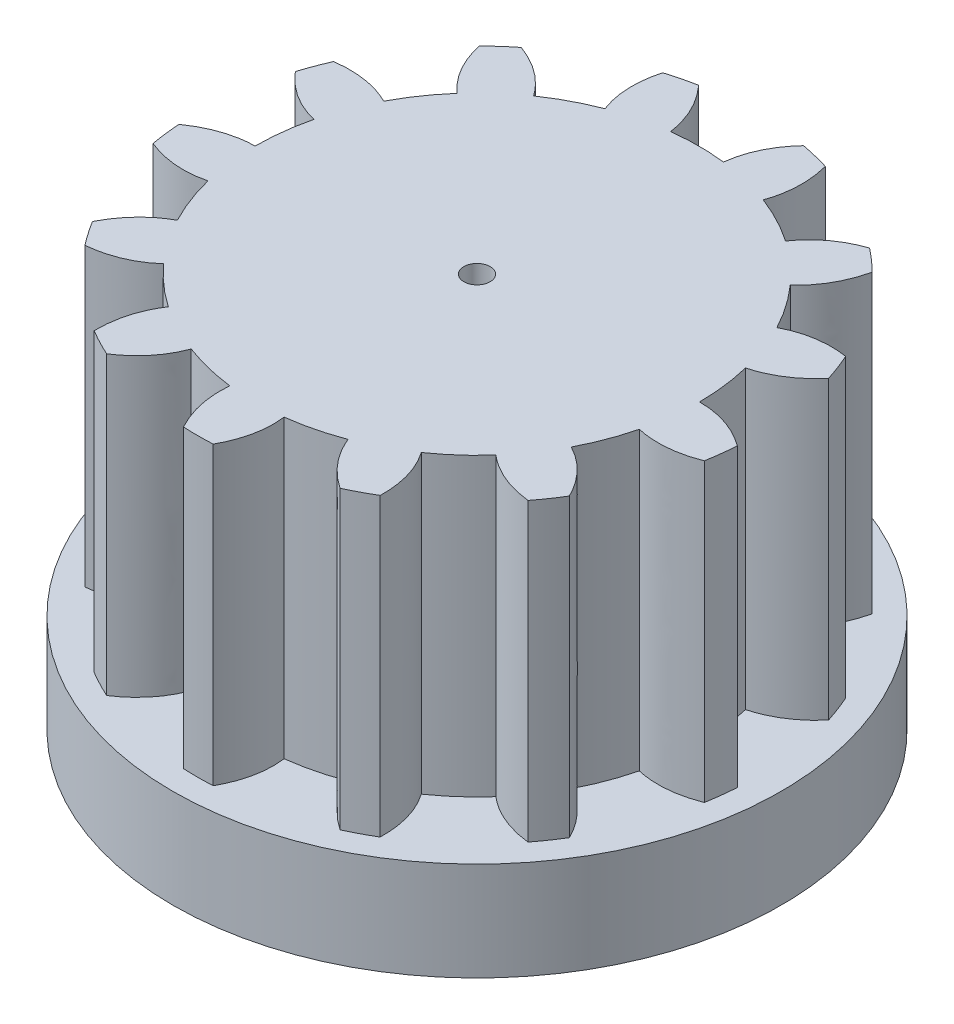
from build123d import *

# Parameters (mm, degrees)
SKETCH1_R           = 0.4
BOSS_EXTRUDE1_DEPTH = 9
SKETCH2_R           = 9.25
BOSS_EXTRUDE2_DEPTH = 3


with BuildPart() as part:
    # Sketch1 → Boss-Extrude1 (new body)
    with BuildSketch(Plane(origin=(0, 0, 0), x_dir=(1, 0, 0), z_dir=(0, 1, 0))):
        with BuildLine():
            add(Edge.make_bspline(
                [(-5.065227978, 4.461610195), (-5.526615005, 4.86619147), (-5.830003112, 5.39406146), (-5.975392301, 6.045220165)],
                knots=[0, 0, 0, 0, 0.872429449, 0.872429449, 0.872429449, 0.872429449], degree=3))
            ThreePointArc((-5.065227978, 4.461610195), (-5.560258819, 3.827012132), (-5.976238464, 3.138004752))
            add(Edge.make_bspline(
                [(-7.780961116, 3.42149735), (-7.125870497, 3.507536778), (-6.52429628, 3.413039245), (-5.976238464, 3.138004752)],
                knots=[0.127683247, 0.127683247, 0.127683247, 0.127683247, 1, 1, 1, 1], degree=3))
            ThreePointArc((-7.780961116, 3.42149735), (-7.951879756, 3.00293329), (-8.10030101, 2.575873357))
            add(Edge.make_bspline(
                [(-6.558450277, 1.596630818), (-7.155006493, 1.740452504), (-7.668956737, 2.066866683), (-8.10030101, 2.575873357)],
                knots=[0, 0, 0, 0, 0.872429449, 0.872429449, 0.872429449, 0.872429449], degree=3))
            ThreePointArc((-6.558450277, 1.596630818), (-6.701865893, 0.804669837), (-6.749999881, 0.00126872))
            add(Edge.make_bspline(
                [(-8.479748007, -0.586407486), (-7.939678588, -0.205787566), (-7.363095879, -0.009895497), (-6.749999881, 0.00126872)],
                knots=[0.127683247, 0.127683247, 0.127683247, 0.127683247, 1, 1, 1, 1], degree=3))
            ThreePointArc((-8.479748007, -0.586407486), (-8.436572529, -1.036457408), (-8.369528376, -1.483574994))
            add(Edge.make_bspline(
                [(-6.549210655, -1.634117437), (-7.144272221, -1.784003157), (-7.751044795, -1.733822342), (-8.369528376, -1.483574994)],
                knots=[0, 0, 0, 0, 0.872429449, 0.872429449, 0.872429449, 0.872429449], degree=3))
            ThreePointArc((-6.549210655, -1.634117437), (-6.308156258, -2.402012621), (-5.977417671, -3.13575796))
            add(Edge.make_bspline(
                [(-7.235926822, -4.459973434), (-6.934601997, -3.871968458), (-6.515098947, -3.4305633), (-5.977417671, -3.13575796)],
                knots=[0.127683247, 0.127683247, 0.127683247, 0.127683247, 1, 1, 1, 1], degree=3))
            ThreePointArc((-7.235926822, -4.459973434), (-6.988548208, -4.838408204), (-6.721397655, -5.203154193))
            add(Edge.make_bspline(
                [(-5.039625799, -4.490509081), (-5.496871281, -4.899765193), (-6.0574619, -5.137313564), (-6.721397655, -5.203154193)],
                knots=[0, 0, 0, 0, 0.872429449, 0.872429449, 0.872429449, 0.872429449], degree=3))
            ThreePointArc((-5.039625799, -4.490509081), (-4.469324045, -5.058422935), (-3.835481109, -5.554420281))
            add(Edge.make_bspline(
                [(-4.334442004, -7.311813216), (-4.34089166, -6.651128039), (-4.174571361, -6.065330394), (-3.835481109, -5.554420281)],
                knots=[0.127683247, 0.127683247, 0.127683247, 0.127683247, 1, 1, 1, 1], degree=3))
            ThreePointArc((-4.334442004, -7.311813216), (-3.939531713, -7.53193799), (-3.533475733, -7.730753472))
            add(Edge.make_bspline(
                [(-2.375523406, -6.318179211), (-2.590203375, -6.893050073), (-2.976187484, -7.36390816), (-3.533475733, -7.730753472)],
                knots=[0, 0, 0, 0, 0.872429449, 0.872429449, 0.872429449, 0.872429449], degree=3))
            ThreePointArc((-2.375523406, -6.318179211), (-1.606623554, -6.556009515), (-0.814882047, -6.700631854))
            add(Edge.make_bspline(
                [(-0.439988759, -8.488604708), (-0.752735357, -7.906594341), (-0.877699786, -7.31060339), (-0.814882047, -6.700631854)],
                knots=[0.127683247, 0.127683247, 0.127683247, 0.127683247, 1, 1, 1, 1], degree=3))
            ThreePointArc((-0.439988759, -8.488604708), (0.011984021, -8.499991552), (0.463922896, -8.487330296))
            add(Edge.make_bspline(
                [(0.832782771, -6.698430626), (0.909848909, -7.307220251), (0.786895617, -7.903520141), (0.463922896, -8.487330296)],
                knots=[0, 0, 0, 0, 0.872429449, 0.872429449, 0.872429449, 0.872429449], degree=3))
            ThreePointArc((0.832782771, -6.698430626), (1.624135031, -6.551693323), (2.392396671, -6.311809421))
            add(Edge.make_bspline(
                [(3.555260608, -7.72075916), (3.007863545, -7.350755165), (2.620242233, -6.881105252), (2.392396671, -6.311809421)],
                knots=[0.127683247, 0.127683247, 0.127683247, 0.127683247, 1, 1, 1, 1], degree=3))
            ThreePointArc((3.555260608, -7.72075916), (3.96075436, -7.520799485), (4.355042381, -7.299562032))
            add(Edge.make_bspline(
                [(3.850308451, -5.54415231), (4.201465773, -6.047394331), (4.369710416, -6.632530905), (4.355042381, -7.299562032)],
                knots=[0, 0, 0, 0, 0.872429449, 0.872429449, 0.872429449, 0.872429449], degree=3))
            ThreePointArc((3.850308451, -5.54415231), (4.482823853, -5.046463148), (5.051606144, -4.477027515))
            add(Edge.make_bspline(
                [(6.736042616, -5.184180734), (6.079397157, -5.110946566), (5.517918333, -4.875228826), (5.051606144, -4.477027515)],
                knots=[0.127683247, 0.127683247, 0.127683247, 0.127683247, 1, 1, 1, 1], degree=3))
            ThreePointArc((6.736042616, -5.184180734), (7.002163607, -4.818682892), (7.24847414, -4.439552076))
            add(Edge.make_bspline(
                [(5.985774866, -3.119775513), (6.530577461, -3.402183249), (6.951477219, -3.84210877), (7.24847414, -4.439552076)],
                knots=[0, 0, 0, 0, 0.872429449, 0.872429449, 0.872429449, 0.872429449], degree=3))
            ThreePointArc((5.985774866, -3.119775513), (6.314551754, -2.385149082), (6.553553527, -1.616612559))
            add(Edge.make_bspline(
                [(8.373678438, -1.459968977), (7.758214146, -1.700281702), (7.151505842, -1.75249623), (6.553553527, -1.616612559)],
                knots=[0.127683247, 0.127683247, 0.127683247, 0.127683247, 1, 1, 1, 1], degree=3))
            ThreePointArc((8.373678438, -1.459968977), (8.439461558, -1.01266412), (8.481367828, -0.562494242))
            add(Edge.make_bspline(
                [(6.749972396, 0.019304256), (7.363612555, 0.022427015), (7.940744366, -0.171505818), (8.481367828, -0.562494242)],
                knots=[0, 0, 0, 0, 0.872429449, 0.872429449, 0.872429449, 0.872429449], degree=3))
            ThreePointArc((6.749972396, 0.019304256), (6.699691947, 0.822573894), (6.554160776, 1.614148852))
            add(Edge.make_bspline(
                [(8.093005444, 2.598704077), (7.65971777, 2.099897208), (7.146769547, 1.771712133), (6.554160776, 1.614148852)],
                knots=[0.127683247, 0.127683247, 0.127683247, 0.127683247, 1, 1, 1, 1], degree=3))
            ThreePointArc((8.093005444, 2.598704077), (7.943380571, 3.025343799), (7.771282357, 3.443424244))
            add(Edge.make_bspline(
                [(5.967832596, 3.153961653), (6.509732754, 3.44189952), (7.110882674, 3.53838705), (7.771282357, 3.443424244)],
                knots=[0, 0, 0, 0, 0.872429449, 0.872429449, 0.872429449, 0.872429449], degree=3))
            ThreePointArc((5.967832596, 3.153961653), (5.550013455, 3.841855105), (5.053288778, 4.475128213))
            add(Edge.make_bspline(
                [(5.958322434, 6.062045345), (5.806472362, 5.419014975), (5.504794477, 4.890042598), (5.053288778, 4.475128213)],
                knots=[0.127683247, 0.127683247, 0.127683247, 0.127683247, 1, 1, 1, 1], degree=3))
            ThreePointArc((5.958322434, 6.062045345), (5.627566824, 6.370281912), (5.280889753, 6.660495734))
            add(Edge.make_bspline(
                [(3.818534268, 5.566084444), (4.16455163, 6.072874324), (4.652003458, 6.437678087), (5.280889753, 6.660495734)],
                knots=[0, 0, 0, 0, 0.872429449, 0.872429449, 0.872429449, 0.872429449], degree=3))
            ThreePointArc((3.818534268, 5.566084444), (3.128893766, 5.98101361), (2.394769219, 6.310909632))
            add(Edge.make_bspline(
                [(2.45865956, 8.136645081), (2.623034112, 7.496701718), (2.601737332, 6.888123235), (2.394769219, 6.310909632)],
                knots=[0.127683247, 0.127683247, 0.127683247, 0.127683247, 1, 1, 1, 1], degree=3))
            ThreePointArc((2.45865956, 8.136645081), (2.022545337, 8.25586521), (1.580708948, 8.351727918))
            add(Edge.make_bspline(
                [(0.794455758, 6.703084368), (0.865321915, 7.312626807), (1.127406312, 7.862174657), (1.580708948, 8.351727918)],
                knots=[0, 0, 0, 0, 0.872429449, 0.872429449, 0.872429449, 0.872429449], degree=3))
            ThreePointArc((0.794455758, 6.703084368), (-0.009017778, 6.749993976), (-0.812363108, 6.700937709))
            add(Edge.make_bspline(
                [(-1.604252589, 8.347237485), (-1.161309642, 7.856984441), (-0.897346481, 7.308217849), (-0.812363108, 6.700937709)],
                knots=[0.127683247, 0.127683247, 0.127683247, 0.127683247, 1, 1, 1, 1], degree=3))
            ThreePointArc((-1.604252589, 8.347237485), (-2.045816912, 8.250129282), (-2.481593228, 8.129679886))
            add(Edge.make_bspline(
                [(-2.411622992, 6.304488444), (-2.632142622, 6.877144615), (-2.655466033, 7.485541762), (-2.481593228, 8.129679886)],
                knots=[0, 0, 0, 0, 0.872429449, 0.872429449, 0.872429449, 0.872429449], degree=3))
            ThreePointArc((-2.411622992, 6.304488444), (-3.144863458, 5.972632069), (-3.833392837, 5.555861712))
            add(Edge.make_bspline(
                [(-5.299649804, 6.645578377), (-4.679611352, 6.417326717), (-4.19085903, 6.054087828), (-3.833392837, 5.555861712)],
                knots=[0.127683247, 0.127683247, 0.127683247, 0.127683247, 1, 1, 1, 1], degree=3))
            ThreePointArc((-5.299649804, 6.645578377), (-5.645507162, 6.35438816), (-5.975392301, 6.045220165))
        make_face()
        Circle(SKETCH1_R, mode=Mode.SUBTRACT)
    extrude(amount=BOSS_EXTRUDE1_DEPTH)

    # Sketch2 → Boss-Extrude2 (add)
    with BuildSketch(Plane.XZ):
        Circle(SKETCH2_R)
    extrude(amount=BOSS_EXTRUDE2_DEPTH)


solid = part.part
